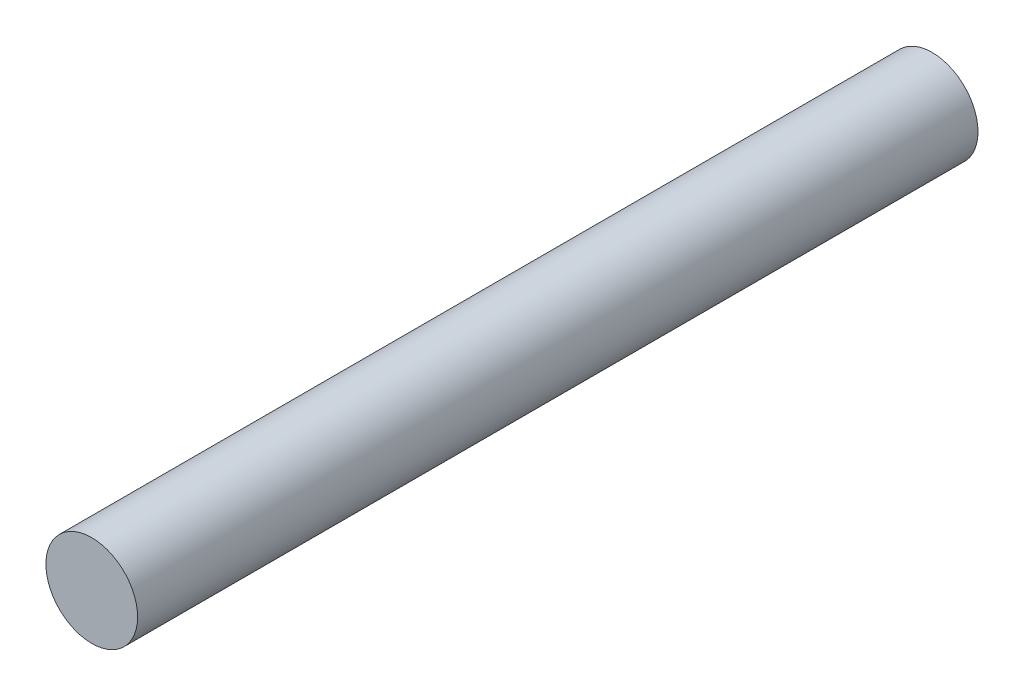
from build123d import *

# Parameters (mm, degrees)
SKETCH1_R  = 3
MAIN_DEPTH = 55


with BuildPart() as part:
    # Sketch1 → Main (new body)
    with BuildSketch(Plane.XY):
        Circle(SKETCH1_R)
    extrude(amount=MAIN_DEPTH)


solid = part.part
